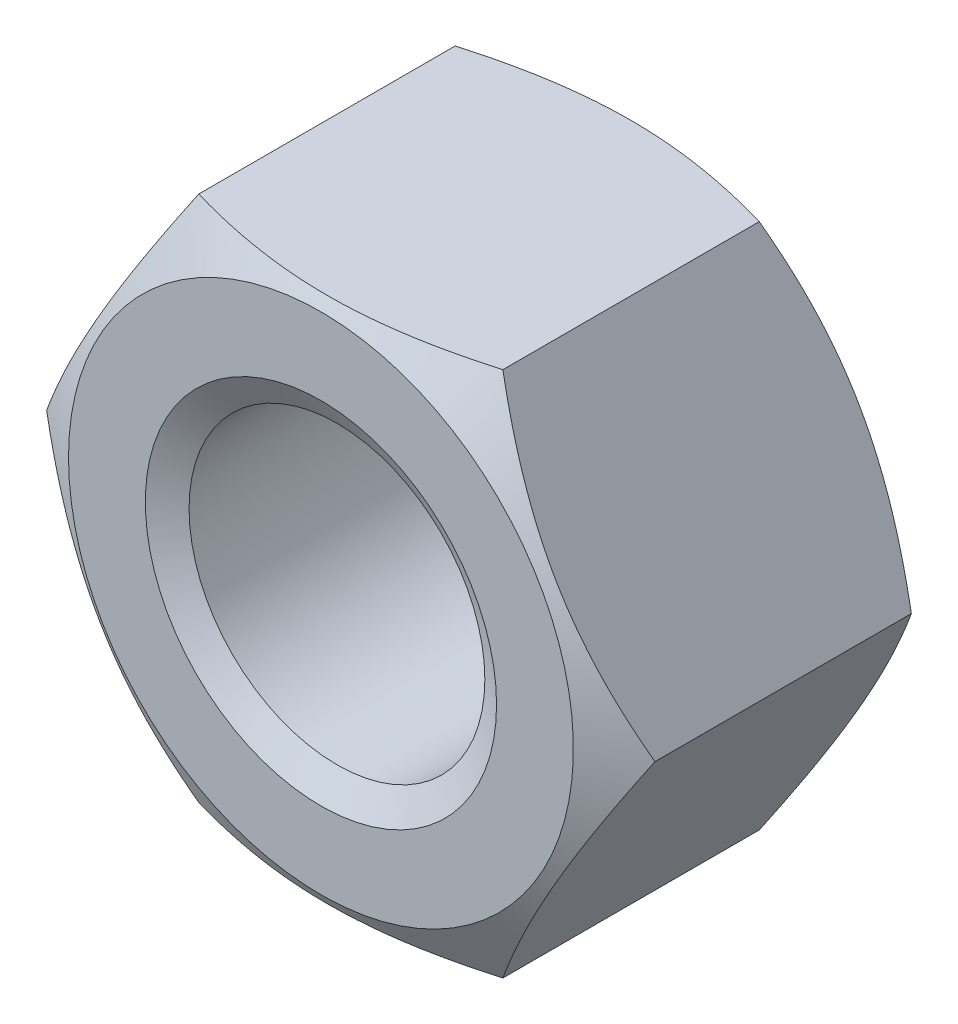
from build123d import *

# Parameters (mm, degrees)
SKETCH1_R               = 5.053
BASENUT_DEPTH           = 10.8
ENDCHAMFER_SIZE         = 0.947
ENDCHAMFER_SIZE2        = 0.546750705
ENDCHAMFER_PART_2_SIZE  = 0.947
ENDCHAMFER_PART_2_SIZE2 = 0.546750705


with BuildPart() as part:
    # Sketch1 → BaseNut (new body)
    with BuildSketch(Plane.XY):
        Polygon((10.392304845, 0), (5.196152423, 9), (-5.196152423, 9), (-10.392304845, 0), (-5.196152423, -9), (5.196152423, -9), align=None)
        Circle(SKETCH1_R, mode=Mode.SUBTRACT)
    extrude(amount=-BASENUT_DEPTH)

    # Sketch2 → Double-Chamfer (revolve, cut)
    with BuildSketch(Plane(origin=(0, 0, 0), x_dir=(1, 0, 0), z_dir=(0, 1, 0))):
        Polygon((-10.392304845, 10.8), (-8.625, 10.8), (-10.392304845, 9.779646072), align=None)
        Polygon((-10.392304845, 1.020353928), (-10.392304845, 0), (-8.625, 0), align=None)
    revolve(axis=Axis((0, 0, -3.375940562), (0, 0, 1)), mode=Mode.SUBTRACT)

    # EndChamfer
    endchamfer_edges = [part.edges().sort_by_distance(p)[0] for p in [
        (-5.053, 0, -10.8),
    ]]
    endchamfer_side = [part.faces().sort_by_distance(p)[0] for p in [
        (-5.053, 0, -5.4),
    ]]
    chamfer(endchamfer_edges, length=ENDCHAMFER_SIZE, length2=ENDCHAMFER_SIZE2, reference=endchamfer_side[0])

    # EndChamfer part 2
    endchamfer_part_2_edges = [part.edges().sort_by_distance(p)[0] for p in [
        (-5.053, 0, 0),
    ]]
    endchamfer_part_2_side = [part.faces().sort_by_distance(p)[0] for p in [
        (8.38104816, 0, 0),
    ]]
    chamfer(endchamfer_part_2_edges, length=ENDCHAMFER_PART_2_SIZE, length2=ENDCHAMFER_PART_2_SIZE2, reference=endchamfer_part_2_side[0])


solid = part.part
